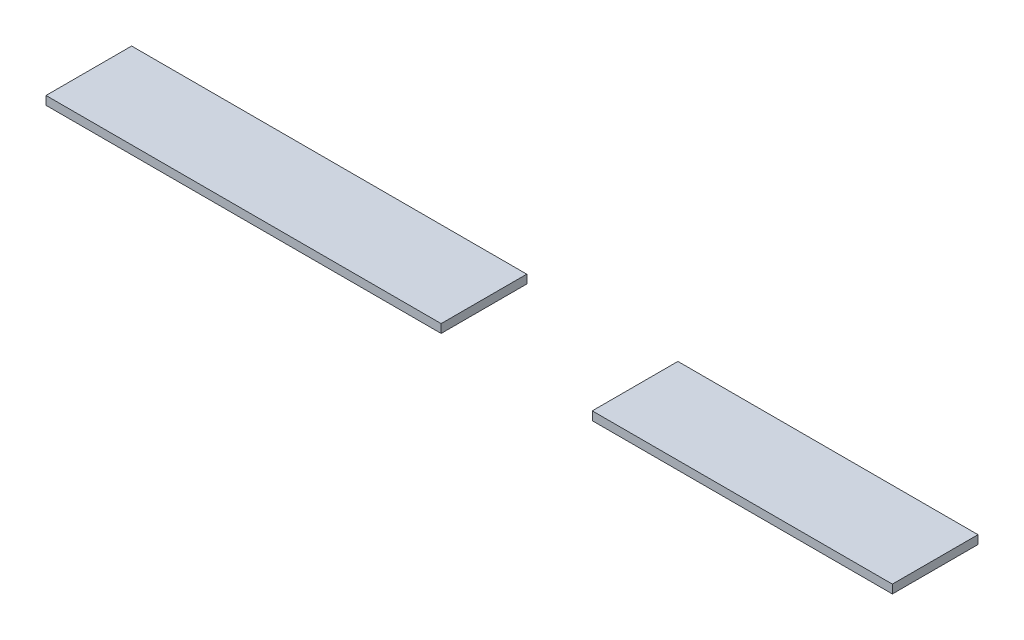
from build123d import *

# Parameters (mm, degrees)
SKETCH1_W           = 197.7
SKETCH1_H           = 20
BOSS_EXTRUDE1_DEPTH = 2
SKETCH3_W           = 25.3
SKETCH3_H           = 20
CUT_EXTRUDE2_DEPTH  = 10
SKETCH4_W           = 5
SKETCH4_H           = 20
CUT_EXTRUDE3_DEPTH  = 10


with BuildPart() as part:
    # Sketch1 → Boss-Extrude1 (new body)
    with BuildSketch(Plane(origin=(0, 0, 0), x_dir=(1, 0, 0), z_dir=(0, 1, 0))):
        with Locations((26.412848541, -2.477865378)):
            Rectangle(SKETCH1_W, SKETCH1_H)
    extrude(amount=BOSS_EXTRUDE1_DEPTH)

    # Sketch3 → Cut-Extrude2 (cut)
    with BuildSketch(Plane(origin=(0, 0, 0), x_dir=(-1, 0, 0), z_dir=(0, -1, 0))):
        with Locations((-37.512848541, -2.477865378)):
            Rectangle(SKETCH3_W, SKETCH3_H)
    extrude(amount=-CUT_EXTRUDE2_DEPTH, mode=Mode.SUBTRACT)

    # Sketch4 → Cut-Extrude3 (cut)
    with BuildSketch(Plane(origin=(0, 0, 0), x_dir=(-1, 0, 0), z_dir=(0, -1, 0))):
        with Locations((-22.362848541, -2.477865378)):
            Rectangle(SKETCH4_W, SKETCH4_H)
        with Locations((-52.662848541, -2.477865378)):
            Rectangle(SKETCH4_W, SKETCH4_H)
    extrude(amount=-CUT_EXTRUDE3_DEPTH, mode=Mode.SUBTRACT)


solid = part.part
